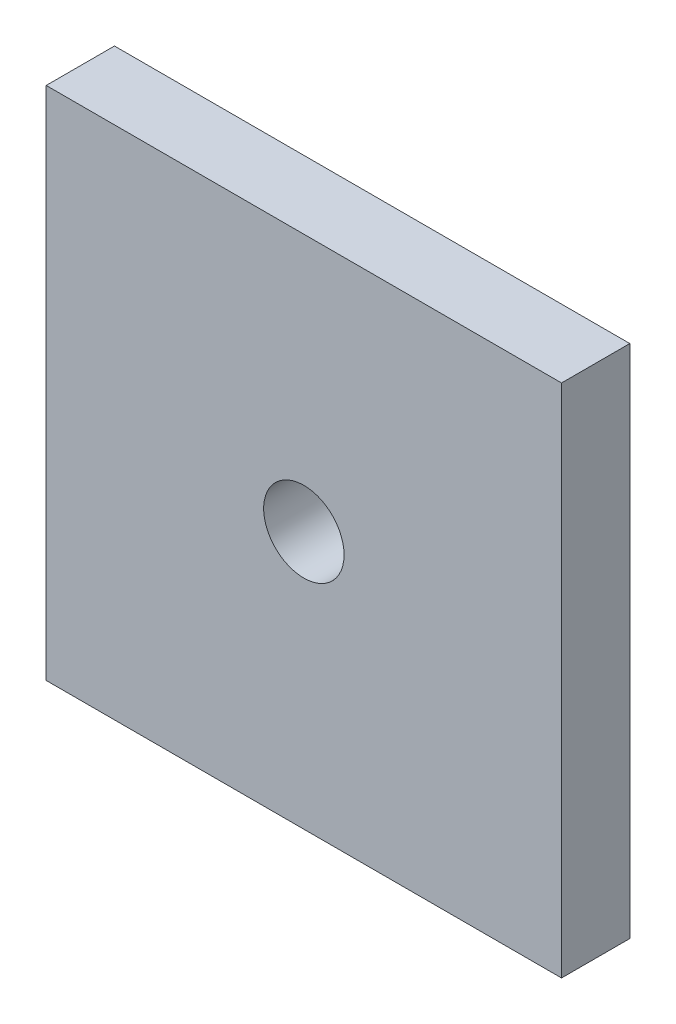
from build123d import *

# Parameters (mm, degrees)
SKETCH2_W           = 50.8
SKETCH2_H           = 50.8
SKETCH2_R           = 3.9624
BOSS_EXTRUDE1_DEPTH = 6.731


with BuildPart() as part:
    # Sketch2 → Boss-Extrude1 (new body)
    with BuildSketch(Plane.XY):
        Rectangle(SKETCH2_W, SKETCH2_H)
        Circle(SKETCH2_R, mode=Mode.SUBTRACT)
    extrude(amount=BOSS_EXTRUDE1_DEPTH)


solid = part.part
